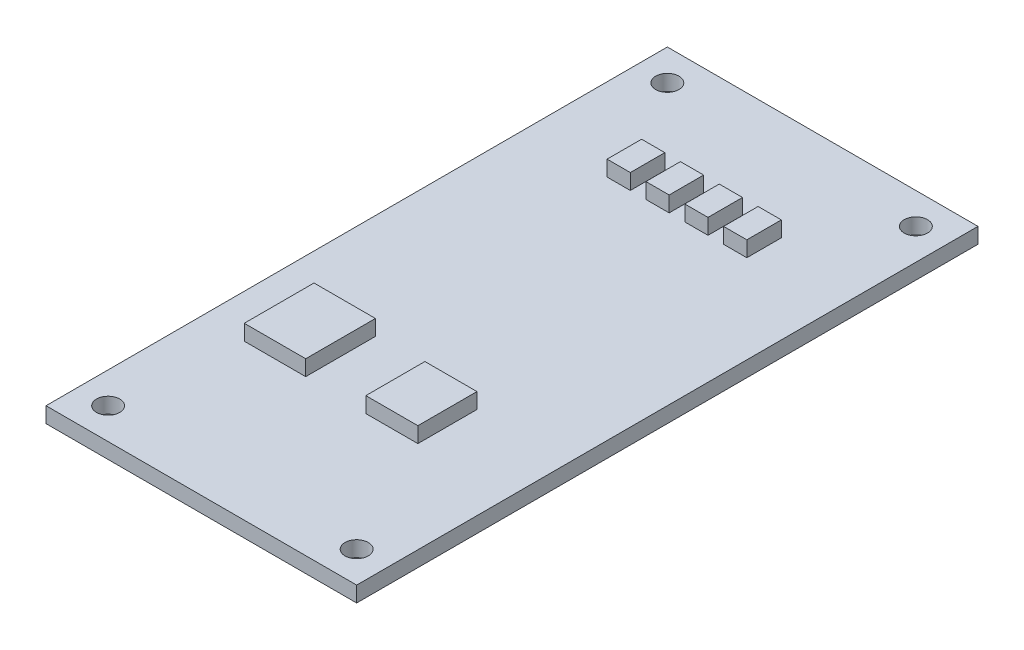
from build123d import *

# Parameters (mm, degrees)
SKETCH_1_W      = 40
SKETCH_1_H      = 80
SKETCH_1_R      = 1.5
EXTRUDE_1_DEPTH = 2
SKETCH_2_W      = 6.701778473
SKETCH_2_H      = 7.607424212
SKETCH_2_W_2    = 7.9099244
SKETCH_2_H_2    = 8.978833102
SKETCH_2_W_3    = 2.99163276
SKETCH_2_H_3    = 4.442525683
EXTRUDE_2_DEPTH = 2


with BuildPart() as part:
    # 草图1 → 凸台-拉伸1 (new body)
    with BuildSketch(Plane(origin=(0, 0, 0), x_dir=(1, 0, 0), z_dir=(0, 1, 0))):
        Rectangle(SKETCH_1_W, SKETCH_1_H)
        with Locations((-16, 36)):
            Circle(SKETCH_1_R, mode=Mode.SUBTRACT)
        with Locations((16, 36)):
            Circle(SKETCH_1_R, mode=Mode.SUBTRACT)
        with Locations((16, -36)):
            Circle(SKETCH_1_R, mode=Mode.SUBTRACT)
        with Locations((-16, -36)):
            Circle(SKETCH_1_R, mode=Mode.SUBTRACT)
    extrude(amount=EXTRUDE_1_DEPTH)

    # 草图2 → 凸台-拉伸2 (add)
    with BuildSketch(Plane(origin=(0, 2, 0), x_dir=(1, 0, 0), z_dir=(0, 1, 0))):
        with Locations((4.815794002, -16.482035575)):
            Rectangle(SKETCH_2_W, SKETCH_2_H)
        with Locations((-10.475305286, -15.552621624)):
            Rectangle(SKETCH_2_W_2, SKETCH_2_H_2)
        with Locations((-7.87829503, 23.838782087)):
            Rectangle(SKETCH_2_W_3, SKETCH_2_H_3)
        with Locations((-2.87829503, 23.838782087)):
            Rectangle(SKETCH_2_W_3, SKETCH_2_H_3)
        with Locations((2.12170497, 23.838782087)):
            Rectangle(SKETCH_2_W_3, SKETCH_2_H_3)
        with Locations((7.12170497, 23.838782087)):
            Rectangle(SKETCH_2_W_3, SKETCH_2_H_3)
    extrude(amount=EXTRUDE_2_DEPTH)


solid = part.part
